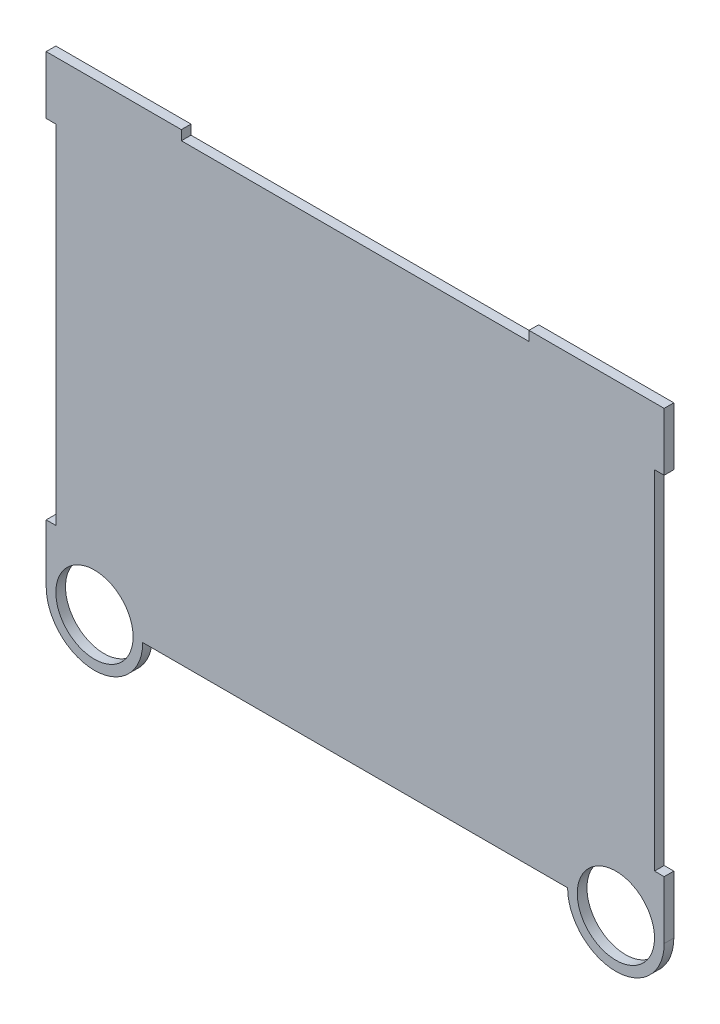
from build123d import *

# Parameters (mm, degrees)
BOSS_EXTRUDE1_DEPTH     = 3.175
SKETCH2_R               = 12.7
CUT_EXTRUDE1_DEPTH      = 1
CUT_EXTRUDE1_DEPTH_BACK = 4.175
SKETCH3_W               = 3.175
SKETCH3_H               = 114.3
SKETCH3_W_2             = 114.3
SKETCH3_H_2             = 3.175
CUT_EXTRUDE2_DEPTH      = 4.175


with BuildPart() as part:
    # Sketch1 → Boss-Extrude1 (new body)
    with BuildSketch(Plane.XY):
        with BuildLine():
            Line((0, 0), (0, 152.4))
            Line((0, 152.4), (203.2, 152.4))
            Line((203.2, 152.4), (203.2, 0))
            ThreePointArc((203.2, 0), (187.325, -15.875), (171.45, 0))
            Line((171.45, 0), (31.75, 0))
            ThreePointArc((31.75, 0), (15.875, -15.875), (0, 0))
        make_face()
    extrude(amount=BOSS_EXTRUDE1_DEPTH)

    # Sketch2 → Cut-Extrude1 (cut, two sides)
    with BuildSketch(Plane.XY.offset(3.175)) as cut_extrude1_sk:
        with Locations((15.875, 0)):
            Circle(SKETCH2_R)
        with Locations((187.325, 0)):
            Circle(SKETCH2_R)
    extrude(amount=CUT_EXTRUDE1_DEPTH, mode=Mode.SUBTRACT)
    extrude(cut_extrude1_sk.sketch, amount=-CUT_EXTRUDE1_DEPTH_BACK, mode=Mode.SUBTRACT)

    # Sketch3 → Cut-Extrude2 (cut, through all)
    with BuildSketch(Plane.XY.offset(3.175)):
        with Locations((201.6125, 76.2)):
            Rectangle(SKETCH3_W, SKETCH3_H)
        with Locations((1.5875, 76.2)):
            Rectangle(SKETCH3_W, SKETCH3_H)
        with Locations((101.6, 150.8125)):
            Rectangle(SKETCH3_W_2, SKETCH3_H_2)
    extrude(amount=-CUT_EXTRUDE2_DEPTH, mode=Mode.SUBTRACT)


solid = part.part
